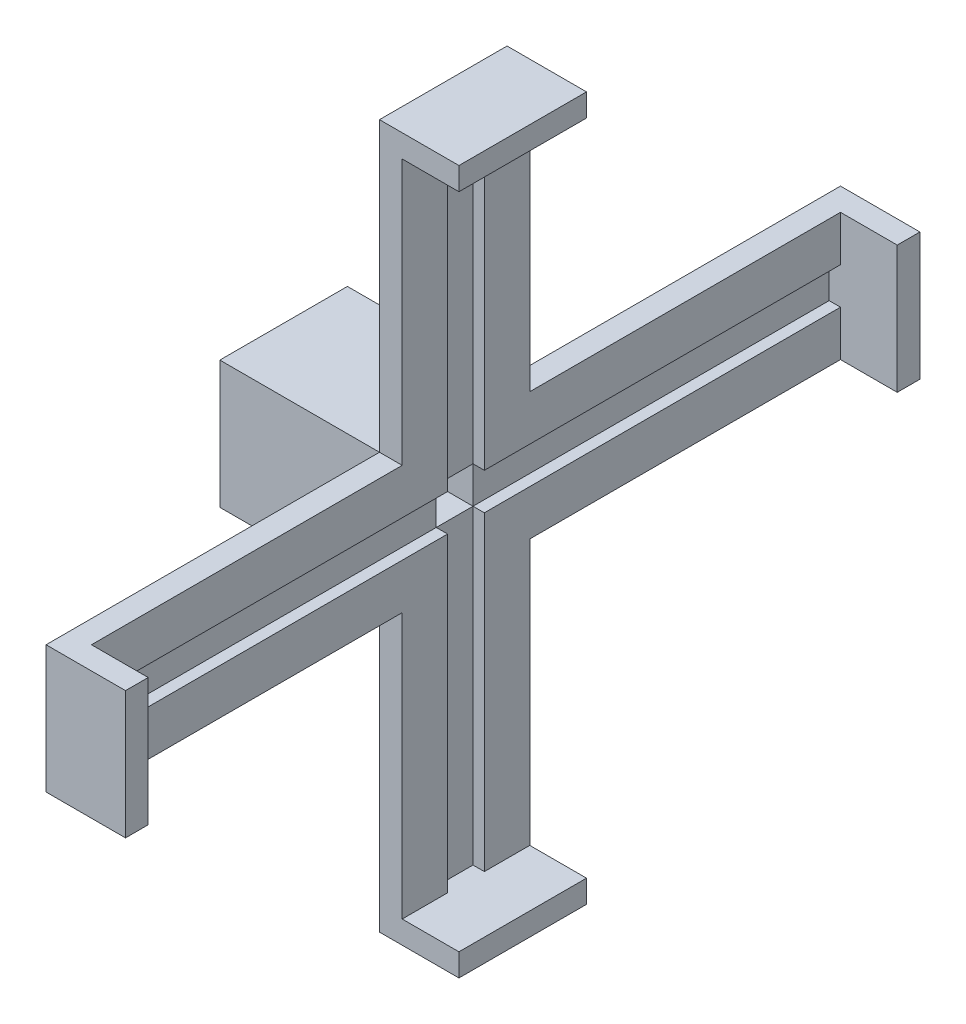
from build123d import *

# Parameters (mm, degrees)
SKETCH1_R            = 28.1
BOSS_EXTRUDE2_DEPTH  = 24
CUT_EXTRUDE2_DEPTH   = 21.5
SKETCH4_R            = 3
CUT_EXTRUDE3_DEPTH   = 9.5
SKETCH6_R            = 6.025
CUT_EXTRUDE4_DEPTH   = 6.2
SKETCH7_W            = 56.2
SKETCH7_H            = 56.2
BOSS_EXTRUDE3_DEPTH  = 56.2
SKETCH8_W            = 56.2
SKETCH8_H            = 56.2
BOSS_EXTRUDE4_DEPTH  = 14.14
SKETCH10_W           = 56.2
SKETCH10_H           = 56.2
BOSS_EXTRUDE5_DEPTH  = 10
SKETCH11_W           = 10
SKETCH11_H           = 56.2
BOSS_EXTRUDE6_DEPTH  = 146.9
SKETCH12_W           = 10
SKETCH12_H           = 56.2
BOSS_EXTRUDE7_DEPTH  = 126.9
SKETCH13_W           = 10
SKETCH13_H           = 56.2
BOSS_EXTRUDE8_DEPTH  = 146.9
SKETCH14_W           = 10
SKETCH14_H           = 56.2
BOSS_EXTRUDE9_DEPTH  = 126.9
SKETCH15_W           = 10
SKETCH15_H           = 56.2
BOSS_EXTRUDE10_DEPTH = 25
SKETCH16_W           = 10
SKETCH16_H           = 56.2
BOSS_EXTRUDE11_DEPTH = 25
SKETCH17_W           = 56.2
SKETCH17_H           = 10
BOSS_EXTRUDE12_DEPTH = 25
SKETCH18_W           = 56.2
SKETCH18_H           = 10
BOSS_EXTRUDE13_DEPTH = 25
SKETCH19_W           = 51.2
SKETCH19_H           = 51.2
CUT_EXTRUDE5_DEPTH   = 63.7
SKETCH23_W           = 330
SKETCH23_H           = 16.2
CUT_EXTRUDE7_DEPTH   = 5
SKETCH24_W           = 16.2
SKETCH24_H           = 290
CUT_EXTRUDE8_DEPTH   = 5
SKETCH25_W           = 16.2
SKETCH25_H           = 16.2
CUT_EXTRUDE12_DEPTH  = 25


with BuildPart() as part:
    # Sketch1 → Boss-Extrude2 (new body)
    with BuildSketch(Plane.XY):
        Circle(SKETCH1_R)
    extrude(amount=BOSS_EXTRUDE2_DEPTH)

    # Sketch3 → Cut-Extrude2 (cut)
    with BuildSketch(Plane(origin=(0, 0, 0), x_dir=(-1, 0, 0), z_dir=(0, 0, -1))):
        with BuildLine():
            Line((-1.661801922, 2.5), (1.661801922, 2.5))
            ThreePointArc((1.661801922, 2.5), (0, -3.001930317), (-1.661801922, 2.5))
        make_face()
    extrude(amount=-CUT_EXTRUDE2_DEPTH, mode=Mode.SUBTRACT)

    # Sketch4 → Cut-Extrude3 (cut)
    with BuildSketch(Plane(origin=(0, 0, 0), x_dir=(-1, 0, 0), z_dir=(0, 0, -1))):
        Circle(SKETCH4_R)
    extrude(amount=-CUT_EXTRUDE3_DEPTH, mode=Mode.SUBTRACT)

    # Sketch6 → Cut-Extrude4 (cut)
    with BuildSketch(Plane(origin=(0, 0, 0), x_dir=(-1, 0, 0), z_dir=(0, 0, -1))):
        Circle(SKETCH6_R)
    extrude(amount=-CUT_EXTRUDE4_DEPTH, mode=Mode.SUBTRACT)

    # Sketch7 → Boss-Extrude3 (add)
    with BuildSketch(Plane.XY.offset(24)):
        Rectangle(SKETCH7_W, SKETCH7_H)
    extrude(amount=BOSS_EXTRUDE3_DEPTH)

    # Sketch8 → Boss-Extrude4 (add)
    with BuildSketch(Plane(origin=(28.1, 0, 0), x_dir=(0, 0, -1), z_dir=(1, 0, 0))):
        with Locations((-52.1, 0)):
            Rectangle(SKETCH8_W, SKETCH8_H)
    extrude(amount=BOSS_EXTRUDE4_DEPTH)

    # Sketch10 → Boss-Extrude5 (add)
    with BuildSketch(Plane(origin=(42.24, 0, 0), x_dir=(0, 0, -1), z_dir=(1, 0, 0))):
        with Locations((-52.1, 0)):
            Rectangle(SKETCH10_W, SKETCH10_H)
    extrude(amount=BOSS_EXTRUDE5_DEPTH)

    # Sketch11 → Boss-Extrude6 (add)
    with BuildSketch(Plane.XY.offset(80.2)):
        with Locations((47.24, 0)):
            Rectangle(SKETCH11_W, SKETCH11_H)
    extrude(amount=BOSS_EXTRUDE6_DEPTH)

    # Sketch12 → Boss-Extrude7 (add)
    with BuildSketch(Plane(origin=(0, 28.1, 0), x_dir=(1, 0, 0), z_dir=(0, 1, 0))):
        with Locations((47.24, -52.1)):
            Rectangle(SKETCH12_W, SKETCH12_H)
    extrude(amount=BOSS_EXTRUDE7_DEPTH)

    # Sketch13 → Boss-Extrude8 (add)
    with BuildSketch(Plane(origin=(0, 0, 24), x_dir=(-1, 0, 0), z_dir=(0, 0, -1))):
        with Locations((-47.24, 0)):
            Rectangle(SKETCH13_W, SKETCH13_H)
    extrude(amount=BOSS_EXTRUDE8_DEPTH)

    # Sketch14 → Boss-Extrude9 (add)
    with BuildSketch(Plane(origin=(0, -28.1, 0), x_dir=(-1, 0, 0), z_dir=(0, -1, 0))):
        with Locations((-47.24, -52.1)):
            Rectangle(SKETCH14_W, SKETCH14_H)
    extrude(amount=BOSS_EXTRUDE9_DEPTH)

    # Sketch15 → Boss-Extrude10 (add)
    with BuildSketch(Plane(origin=(52.24, 0, 0), x_dir=(0, 0, -1), z_dir=(1, 0, 0))):
        with Locations((-222.1, 0)):
            Rectangle(SKETCH15_W, SKETCH15_H)
    extrude(amount=BOSS_EXTRUDE10_DEPTH)

    # Sketch16 → Boss-Extrude11 (add)
    with BuildSketch(Plane(origin=(52.24, 0, 0), x_dir=(0, 0, -1), z_dir=(1, 0, 0))):
        with Locations((117.9, 0)):
            Rectangle(SKETCH16_W, SKETCH16_H)
    extrude(amount=BOSS_EXTRUDE11_DEPTH)

    # Sketch17 → Boss-Extrude12 (add)
    with BuildSketch(Plane(origin=(52.24, 0, 0), x_dir=(0, 0, -1), z_dir=(1, 0, 0))):
        with Locations((-52.1, 150)):
            Rectangle(SKETCH17_W, SKETCH17_H)
    extrude(amount=BOSS_EXTRUDE12_DEPTH)

    # Sketch18 → Boss-Extrude13 (add)
    with BuildSketch(Plane(origin=(52.24, 0, 0), x_dir=(0, 0, -1), z_dir=(1, 0, 0))):
        with Locations((-52.1, -150)):
            Rectangle(SKETCH18_W, SKETCH18_H)
    extrude(amount=BOSS_EXTRUDE13_DEPTH)

    # Sketch19 → Cut-Extrude5 (cut)
    with BuildSketch(Plane.ZY.offset(28.1)):
        with Locations((52.1, 0)):
            Rectangle(SKETCH19_W, SKETCH19_H)
    extrude(amount=-CUT_EXTRUDE5_DEPTH, mode=Mode.SUBTRACT)

    # Cut-Sweep2: sweep along a path in Sketch20
    with BuildLine(Plane(origin=(0, 0, 0), x_dir=(-1, 0, 0), z_dir=(0, 0, -1))) as cut_sweep2_path:
        ThreePointArc((0, 15), (-10.606601718, 10.606601718), (-15, 0))
    # 3DSketch2 → Cut-Sweep2 (sweep, cut)
    with BuildSketch(Plane(origin=(0, 15, 0), x_dir=(0, 0.17521220324553322, 0.9845306921746249), z_dir=(-1, 0, 0))):
        Polygon((0, 0), (1.314091524, 7.383980191), (42.805237655, 0), (41.491146131, -7.383980191), align=None)
    sweep(path=cut_sweep2_path.line, mode=Mode.SUBTRACT)

    # Sketch23 → Cut-Extrude7 (cut)
    with BuildSketch(Plane(origin=(52.24, 0, 0), x_dir=(0, 0, -1), z_dir=(1, 0, 0))):
        with Locations((-52.1, 0)):
            Rectangle(SKETCH23_W, SKETCH23_H)
    extrude(amount=-CUT_EXTRUDE7_DEPTH, mode=Mode.SUBTRACT)

    # Sketch24 → Cut-Extrude8 (cut)
    with BuildSketch(Plane(origin=(52.24, 0, 0), x_dir=(0, 0, -1), z_dir=(1, 0, 0))):
        with Locations((-52.1, 0)):
            Rectangle(SKETCH24_W, SKETCH24_H)
    extrude(amount=-CUT_EXTRUDE8_DEPTH, mode=Mode.SUBTRACT)

    # Sketch25 → Cut-Extrude12 (cut)
    with BuildSketch(Plane(origin=(47.24, 0, 0), x_dir=(0, 0, -1), z_dir=(1, 0, 0))):
        with Locations((-52.1, 0)):
            Rectangle(SKETCH25_W, SKETCH25_H)
    extrude(amount=-CUT_EXTRUDE12_DEPTH, mode=Mode.SUBTRACT)


solid = part.part
